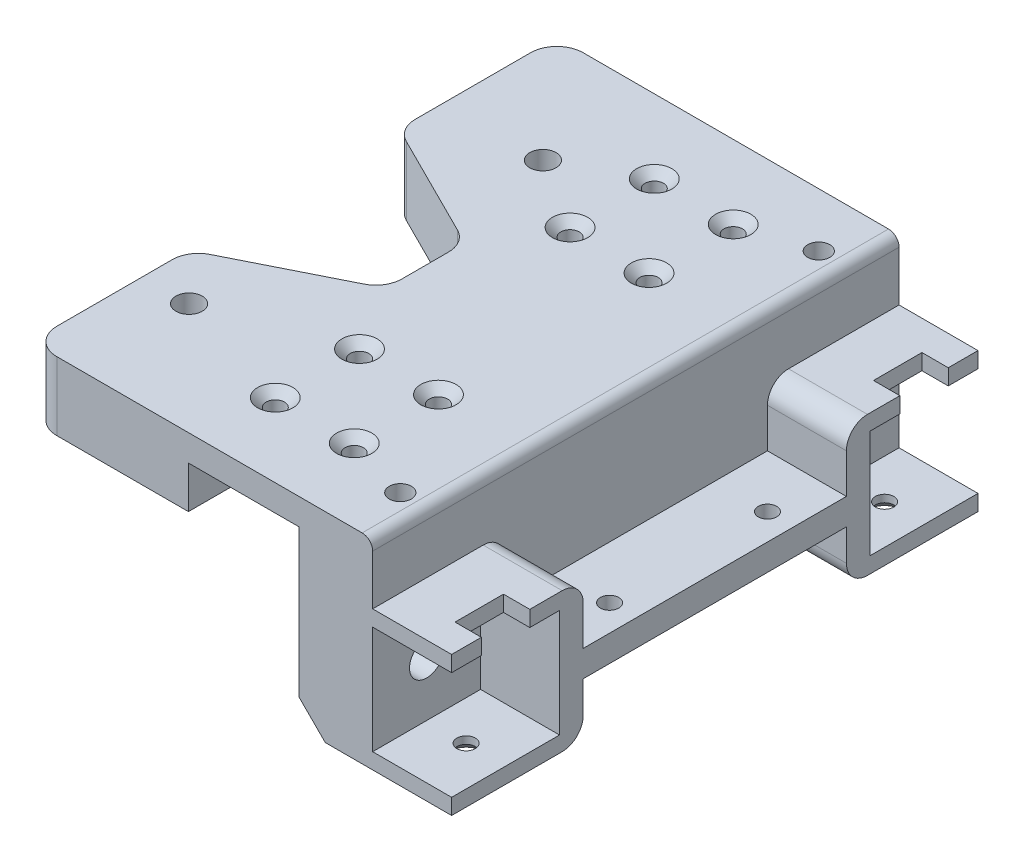
from build123d import *

# Parameters (mm, degrees)
SKETCH1_R           = 1.75
BOSS_EXTRUDE1_DEPTH = 5
SKETCH2_W           = 100
SKETCH2_H           = 38
BOSS_EXTRUDE2_DEPTH = 14
SKETCH3_W           = 50
SKETCH3_H           = 5
BOSS_EXTRUDE3_DEPTH = 15
SKETCH4_R           = 1.75
CUT_EXTRUDE1_DEPTH  = 16
BOSS_EXTRUDE6_DEPTH = 15
SKETCH9_R           = 3.25
CUT_EXTRUDE3_DEPTH  = 36
SKETCH10_R          = 5.25
CUT_EXTRUDE4_DEPTH  = 9
CUT_EXTRUDE5_REACH  = 28.5
SKETCH11_W          = 5
SKETCH11_H          = 9.2
SKETCH12_R          = 1.75
CUT_EXTRUDE6_DEPTH  = 4
SKETCH13_W          = 100
SKETCH13_H          = 13
BOSS_EXTRUDE7_DEPTH = 30
SKETCH14_R          = 2.5
CUT_EXTRUDE7_DEPTH  = 39
CUT_EXTRUDE8_DEPTH  = 4
SKETCH16_R          = 2.1
CUT_EXTRUDE9_DEPTH  = 4
CHAMFER1_SIZE       = 1.6
CUT_EXTRUDE10_DEPTH = 39
CHAMFER2_SIZE       = 1.6
CHAMFER3_SIZE       = 5
SKETCH18_R          = 1.75
CUT_EXTRUDE11_DEPTH = 4
FILLET1_R           = 5
FILLET2_R           = 2
FILLET3_R           = 4


with BuildPart() as part:
    # Sketch1 → Boss-Extrude1 (new body)
    with BuildSketch(Plane(origin=(0, 0, 0), x_dir=(1, 0, 0), z_dir=(0, 1, 0))):
        Polygon((-10, 50), (10, 50), (11, 50), (11, -50), (10, -50), (-10, -50), align=None)
        with Locations((-7.5, 36)):
            Circle(SKETCH1_R, mode=Mode.SUBTRACT)
        with Locations((7.5, 36)):
            Circle(SKETCH1_R, mode=Mode.SUBTRACT)
        with Locations((-7.5, 20)):
            Circle(SKETCH1_R, mode=Mode.SUBTRACT)
        with Locations((7.5, 20)):
            Circle(SKETCH1_R, mode=Mode.SUBTRACT)
        with Locations((7.5, -20)):
            Circle(SKETCH1_R, mode=Mode.SUBTRACT)
        with Locations((-7.5, -20)):
            Circle(SKETCH1_R, mode=Mode.SUBTRACT)
        with Locations((7.5, -36)):
            Circle(SKETCH1_R, mode=Mode.SUBTRACT)
        with Locations((-7.5, -36)):
            Circle(SKETCH1_R, mode=Mode.SUBTRACT)
    extrude(amount=BOSS_EXTRUDE1_DEPTH)

    # Sketch2 → Boss-Extrude2 (add)
    with BuildSketch(Plane(origin=(11, 0, 0), x_dir=(0, 0, -1), z_dir=(1, 0, 0))):
        with Locations((0, -14)):
            Rectangle(SKETCH2_W, SKETCH2_H)
    extrude(amount=BOSS_EXTRUDE2_DEPTH)

    # Sketch3 → Boss-Extrude3 (add)
    with BuildSketch(Plane(origin=(25, 0, 0), x_dir=(0, 0, -1), z_dir=(1, 0, 0))):
        with Locations((0, -20.5)):
            Rectangle(SKETCH3_W, SKETCH3_H)
    extrude(amount=BOSS_EXTRUDE3_DEPTH)

    # Sketch4 → Cut-Extrude1 (cut, through all)
    with BuildSketch(Plane(origin=(0, -18, 0), x_dir=(1, 0, 0), z_dir=(0, 1, 0))):
        with Locations((35, 15)):
            Circle(SKETCH4_R)
        with Locations((35, -15)):
            Circle(SKETCH4_R)
    extrude(amount=-CUT_EXTRUDE1_DEPTH, mode=Mode.SUBTRACT)

    # Sketch8 → Boss-Extrude6 (add)
    with BuildSketch(Plane(origin=(25, 0, 0), x_dir=(0, 0, -1), z_dir=(1, 0, 0))):
        Polygon((-50, -6.5), (-25, -6.5), (-25, -33), (-50, -33), (-50, -30), (-29.5, -30), (-29.5, -9.5), (-50, -9.5), align=None)
        Polygon((29.5, -30), (29.5, -9.5), (50, -9.5), (50, -6.5), (25, -6.5), (25, -33), (50, -33), (50, -30), align=None)
    extrude(amount=BOSS_EXTRUDE6_DEPTH)

    # Sketch9 → Cut-Extrude3 (cut, through all)
    with BuildSketch(Plane(origin=(25, 0, 0), x_dir=(0, 0, -1), z_dir=(1, 0, 0))):
        with Locations((-39.75, -19.75)):
            Circle(SKETCH9_R)
        with Locations((39.75, -19.75)):
            Circle(SKETCH9_R)
    extrude(amount=-CUT_EXTRUDE3_DEPTH, mode=Mode.SUBTRACT)

    # Sketch10 → Cut-Extrude4 (cut)
    with BuildSketch(Plane.ZY.offset(-11)):
        with Locations((-39.75, -19.75)):
            Circle(SKETCH10_R)
        with Locations((39.75, -19.75)):
            Circle(SKETCH10_R)
    extrude(amount=-CUT_EXTRUDE4_DEPTH, mode=Mode.SUBTRACT)

    # Sketch11 → Cut-Extrude5 (cut, up to next)
    with BuildSketch(Plane(origin=(0, -6.5, 0), x_dir=(1, 0, 0), z_dir=(0, 1, 0)), mode=Mode.PRIVATE) as cut_extrude5_sk1:
        with Locations((37.5, -39.75)):
            Rectangle(SKETCH11_W, SKETCH11_H)
    cut_extrude5_tool1 = extrude(cut_extrude5_sk1.sketch, amount=-CUT_EXTRUDE5_REACH, mode=Mode.PRIVATE) & part.part
    add(cut_extrude5_tool1.solids().sort_by_distance((37.5, -6.5, 39.75))[0], mode=Mode.SUBTRACT)
    # Sketch11 → Cut-Extrude5 (cut, up to next)
    with BuildSketch(Plane(origin=(0, -6.5, 0), x_dir=(1, 0, 0), z_dir=(0, 1, 0)), mode=Mode.PRIVATE) as cut_extrude5_sk2:
        with Locations((37.5, 39.75)):
            Rectangle(SKETCH11_W, SKETCH11_H)
    cut_extrude5_tool2 = extrude(cut_extrude5_sk2.sketch, amount=-CUT_EXTRUDE5_REACH, mode=Mode.PRIVATE) & part.part
    add(cut_extrude5_tool2.solids().sort_by_distance((37.5, -6.5, -39.75))[0], mode=Mode.SUBTRACT)

    # Sketch12 → Cut-Extrude6 (cut, through all)
    with BuildSketch(Plane(origin=(0, -30, 0), x_dir=(1, 0, 0), z_dir=(0, 1, 0))):
        with Locations((32.5, -39.75)):
            Circle(SKETCH12_R)
        with Locations((32.5, 39.75)):
            Circle(SKETCH12_R)
    extrude(amount=-CUT_EXTRUDE6_DEPTH, mode=Mode.SUBTRACT)

    # Sketch13 → Boss-Extrude7 (add)
    with BuildSketch(Plane.ZY.offset(10)):
        with Locations((0, -1.5)):
            Rectangle(SKETCH13_W, SKETCH13_H)
    extrude(amount=BOSS_EXTRUDE7_DEPTH)

    # Sketch14 → Cut-Extrude7 (cut, through all)
    with BuildSketch(Plane(origin=(0, 5, 0), x_dir=(1, 0, 0), z_dir=(0, 1, 0))):
        with Locations((-21.15, 28.4925)):
            Circle(SKETCH14_R)
        with Locations((-31.1525, -28.725)):
            Circle(SKETCH14_R)
    extrude(amount=-CUT_EXTRUDE7_DEPTH, mode=Mode.SUBTRACT)

    # Sketch15 → Cut-Extrude8 (cut)
    with BuildSketch(Plane.XZ.offset(8)):
        Polygon((-27.1525, 26.415598923), (-27.1525, 31.034401077), (-31.1525, 33.343802154), (-35.1525, 31.034401077), (-35.1525, 26.415598923), (-31.1525, 24.106197846), align=None)
        Polygon((-25.15, -30.801901077), (-21.15, -33.111302154), (-17.15, -30.801901077), (-17.15, -26.183098923), (-21.15, -23.873697846), (-25.15, -26.183098923), align=None)
    extrude(amount=-CUT_EXTRUDE8_DEPTH, mode=Mode.SUBTRACT)

    # Sketch16 → Cut-Extrude9 (cut)
    with BuildSketch(Plane(origin=(0, 5, 0), x_dir=(1, 0, 0), z_dir=(0, 1, 0))):
        with Locations((20, 39.75)):
            Circle(SKETCH16_R)
        with Locations((20, -39.75)):
            Circle(SKETCH16_R)
    extrude(amount=-CUT_EXTRUDE9_DEPTH, mode=Mode.SUBTRACT)

    # Chamfer1
    chamfer1_edges = [part.edges().sort_by_distance(p)[0] for p in [
        (-9.25, 5, -36),
        (5.75, 5, -36),
        (-9.25, 5, -20),
        (5.75, 5, -20),
        (5.75, 5, 20),
        (-9.25, 5, 20),
        (5.75, 5, 36),
        (-9.25, 5, 36),
    ]]
    chamfer(chamfer1_edges, length=CHAMFER1_SIZE)

    # Sketch17 → Cut-Extrude10 (cut, through all)
    with BuildSketch(Plane(origin=(0, 5, 0), x_dir=(1, 0, 0), z_dir=(0, 1, 0))):
        Polygon((-40, 20), (-15, 7.5), (-15, -7.5), (-40, -20), align=None)
    extrude(amount=-CUT_EXTRUDE10_DEPTH, mode=Mode.SUBTRACT)

    # Chamfer2
    chamfer2_edges = [part.edges().sort_by_distance(p)[0] for p in [
        (30.75, -33, 39.75),
        (30.75, -33, -39.75),
    ]]
    chamfer(chamfer2_edges, length=CHAMFER2_SIZE)

    # Chamfer3
    chamfer3_edges = [part.edges().sort_by_distance(p)[0] for p in [
        (11, -33, 0),
    ]]
    chamfer(chamfer3_edges, length=CHAMFER3_SIZE)

    # Sketch18 → Cut-Extrude11 (cut)
    with BuildSketch(Plane(origin=(0, 1, 0), x_dir=(1, 0, 0), z_dir=(0, 1, 0))):
        with Locations((20, 39.75)):
            Circle(SKETCH18_R)
        with Locations((20, -39.75)):
            Circle(SKETCH18_R)
    extrude(amount=-CUT_EXTRUDE11_DEPTH, mode=Mode.SUBTRACT)

    # Fillet1
    fillet1_edges = [part.edges().sort_by_distance(p)[0] for p in [
        (-40, -1.5, -50),
        (-40, -1.5, 50),
        (-40, -1.5, 20),
        (-40, -1.5, -20),
        (-15, -1.5, -7.5),
        (-15, -1.5, 7.5),
    ]]
    fillet(fillet1_edges, radius=FILLET1_R)

    # Fillet2
    fillet2_edges = [part.edges().sort_by_distance(p)[0] for p in [
        (25, 5, 0),
    ]]
    fillet(fillet2_edges, radius=FILLET2_R)

    # Fillet3
    fillet3_edges = [part.edges().sort_by_distance(p)[0] for p in [
        (32.5, -6.5, -25),
        (32.5, -33, -25),
        (32.5, -33, 25),
        (32.5, -6.5, 25),
    ]]
    fillet(fillet3_edges, radius=FILLET3_R)


solid = part.part
